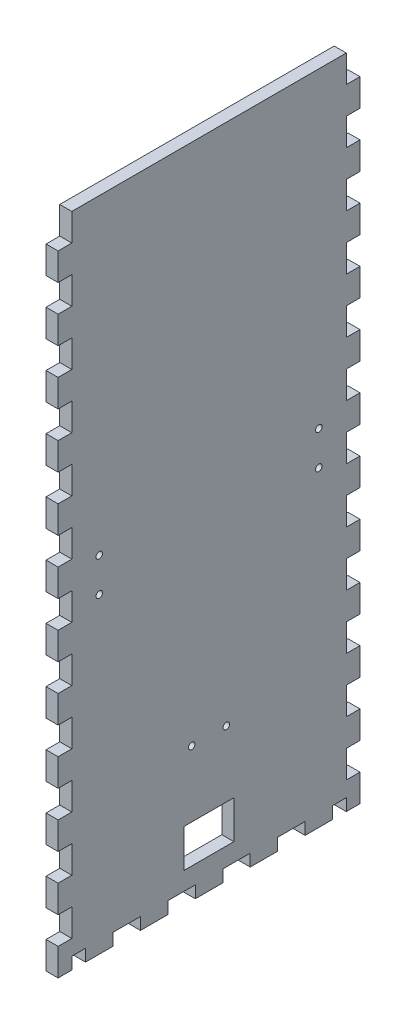
from build123d import *

# Parameters (mm, degrees)
SKETCH1_W              = 273.05
SKETCH1_H              = 139.7
BOSS_EXTRUDE1_DEPTH    = 5.588
SKETCH2_W              = 273.05
SKETCH2_H              = 139.7
SKETCH2_W_2            = 261.874
SKETCH2_H_2            = 128.524
BOSS_EXTRUDE2_DEPTH    = 298.45
SKETCH3_W              = 6.35
SKETCH3_H              = 16.933333333
SKETCH3_H_2            = 16.933333334
DOOR_SLOT_DEPTH        = 12.7
DOOR_GUIDE_HOLES_REACH = 361.255
SKETCH4_W              = 6.35
SKETCH4_H              = 15.875
LEVER_HOLES_W          = 9.652
LEVER_HOLES_H          = 6.35
LEVER_HOLES_W_2        = 6.35
CUT_EXTRUDE1_DEPTH     = 362.378293578
CUT_EXTRUDE3_REACH     = 416.577
SKETCH8_R              = 3.175
SKETCH16_W             = 327.238778096
SKETCH16_H             = 314.471565403
CUT_EXTRUDE10_DEPTH    = 362.378293578
LEFT_RIGHT_W           = 6.35
LEFT_RIGHT_H           = 5.588
LEFT_RIGHT_W_2         = 12.7
LEFT_RIGHT_H_2         = 12.66825
CUT_EXTRUDE11_DEPTH    = 415.577411883
SKETCH17_R             = 1.5
SKETCH17_W             = 23
SKETCH17_H             = 17.61800007
CUT_EXTRUDE12_DEPTH    = 313.00857951


with BuildPart() as part:
    # Sketch1 → Boss-Extrude1 (new body)
    with BuildSketch(Plane(origin=(0, 0, 0), x_dir=(1, 0, 0), z_dir=(0, 1, 0))):
        Rectangle(SKETCH1_W, SKETCH1_H)
    extrude(amount=BOSS_EXTRUDE1_DEPTH)

    # Sketch2 → Boss-Extrude2 (add)
    with BuildSketch(Plane(origin=(0, 5.588, 0), x_dir=(1, 0, 0), z_dir=(0, 1, 0))):
        Rectangle(SKETCH2_W, SKETCH2_H)
        Rectangle(SKETCH2_W_2, SKETCH2_H_2, mode=Mode.SUBTRACT)
    extrude(amount=BOSS_EXTRUDE2_DEPTH)

    # Sketch3 → Door Slot (cut)
    with BuildSketch(Plane.XY.offset(69.85)):
        with BuildLine():
            Line((-29.337, 282.448), (-29.337, 5.588))
            Line((-29.337, 5.588), (-22.733, 5.588))
            Line((-22.733, 5.588), (-22.733, 291.592))
            Line((-22.733, 291.592), (-42.291, 291.592))
            Line((-42.291, 291.592), (-42.291, 284.988))
            Line((-42.291, 284.988), (-31.877, 284.988))
            ThreePointArc((-31.877, 284.988), (-30.080948776, 284.244051224), (-29.337, 282.448))
        make_face()
        with Locations((-13.208, 80.433333334)):
            Rectangle(SKETCH3_W, SKETCH3_H)
        with Locations((-13.208, 50.8)):
            Rectangle(SKETCH3_W, SKETCH3_H_2)
        with Locations((-13.208, 21.166666667)):
            Rectangle(SKETCH3_W, SKETCH3_H)
    extrude(amount=-DOOR_SLOT_DEPTH, mode=Mode.SUBTRACT)

    # Sketch4 → Door Guide Holes (cut, up to next)
    with BuildSketch(Plane.XY.offset(-64.262), mode=Mode.PRIVATE) as door_guide_holes_sk1:
        with Locations((-45.466, 283.4005)):
            Rectangle(SKETCH4_W, SKETCH4_H)
    door_guide_holes_tool1 = extrude(door_guide_holes_sk1.sketch, amount=-DOOR_GUIDE_HOLES_REACH, mode=Mode.PRIVATE) & part.part
    # Sketch4 → Door Guide Holes (cut, up to next)
    with BuildSketch(Plane.XY.offset(-64.262), mode=Mode.PRIVATE) as door_guide_holes_sk2:
        with Locations((-45.466, 254.8255)):
            Rectangle(SKETCH4_W, SKETCH4_H)
    door_guide_holes_tool2 = extrude(door_guide_holes_sk2.sketch, amount=-DOOR_GUIDE_HOLES_REACH, mode=Mode.PRIVATE) & part.part
    # Sketch4 → Door Guide Holes (cut, up to next)
    with BuildSketch(Plane.XY.offset(-64.262), mode=Mode.PRIVATE) as door_guide_holes_sk3:
        with Locations((-45.466, 226.2505)):
            Rectangle(SKETCH4_W, SKETCH4_H)
    door_guide_holes_tool3 = extrude(door_guide_holes_sk3.sketch, amount=-DOOR_GUIDE_HOLES_REACH, mode=Mode.PRIVATE) & part.part
    # Sketch4 → Door Guide Holes (cut, up to next)
    with BuildSketch(Plane.XY.offset(-64.262), mode=Mode.PRIVATE) as door_guide_holes_sk4:
        with Locations((-45.466, 197.6755)):
            Rectangle(SKETCH4_W, SKETCH4_H)
    door_guide_holes_tool4 = extrude(door_guide_holes_sk4.sketch, amount=-DOOR_GUIDE_HOLES_REACH, mode=Mode.PRIVATE) & part.part
    # Sketch4 → Door Guide Holes (cut, up to next)
    with BuildSketch(Plane.XY.offset(-64.262), mode=Mode.PRIVATE) as door_guide_holes_sk5:
        with Locations((-45.466, 169.1005)):
            Rectangle(SKETCH4_W, SKETCH4_H)
    door_guide_holes_tool5 = extrude(door_guide_holes_sk5.sketch, amount=-DOOR_GUIDE_HOLES_REACH, mode=Mode.PRIVATE) & part.part
    # Sketch4 → Door Guide Holes (cut, up to next)
    with BuildSketch(Plane.XY.offset(-64.262), mode=Mode.PRIVATE) as door_guide_holes_sk6:
        with Locations((-45.466, 140.5255)):
            Rectangle(SKETCH4_W, SKETCH4_H)
    door_guide_holes_tool6 = extrude(door_guide_holes_sk6.sketch, amount=-DOOR_GUIDE_HOLES_REACH, mode=Mode.PRIVATE) & part.part
    # Sketch4 → Door Guide Holes (cut, up to next)
    with BuildSketch(Plane.XY.offset(-64.262), mode=Mode.PRIVATE) as door_guide_holes_sk7:
        with Locations((-45.466, 111.9505)):
            Rectangle(SKETCH4_W, SKETCH4_H)
    door_guide_holes_tool7 = extrude(door_guide_holes_sk7.sketch, amount=-DOOR_GUIDE_HOLES_REACH, mode=Mode.PRIVATE) & part.part
    # Sketch4 → Door Guide Holes (cut, up to next)
    with BuildSketch(Plane.XY.offset(-64.262), mode=Mode.PRIVATE) as door_guide_holes_sk8:
        with Locations((-45.466, 83.3755)):
            Rectangle(SKETCH4_W, SKETCH4_H)
    door_guide_holes_tool8 = extrude(door_guide_holes_sk8.sketch, amount=-DOOR_GUIDE_HOLES_REACH, mode=Mode.PRIVATE) & part.part
    # Sketch4 → Door Guide Holes (cut, up to next)
    with BuildSketch(Plane.XY.offset(-64.262), mode=Mode.PRIVATE) as door_guide_holes_sk9:
        with Locations((-45.466, 54.8005)):
            Rectangle(SKETCH4_W, SKETCH4_H)
    door_guide_holes_tool9 = extrude(door_guide_holes_sk9.sketch, amount=-DOOR_GUIDE_HOLES_REACH, mode=Mode.PRIVATE) & part.part
    # Sketch4 → Door Guide Holes (cut, up to next)
    with BuildSketch(Plane.XY.offset(-64.262), mode=Mode.PRIVATE) as door_guide_holes_sk10:
        with Locations((-45.466, 26.2255)):
            Rectangle(SKETCH4_W, SKETCH4_H)
    door_guide_holes_tool10 = extrude(door_guide_holes_sk10.sketch, amount=-DOOR_GUIDE_HOLES_REACH, mode=Mode.PRIVATE) & part.part
    door_guide_holes_1 = door_guide_holes_tool1.solids().sort_by_distance((-45.466, 283.4005, -64.262))[0]
    add(door_guide_holes_1, mode=Mode.SUBTRACT)
    door_guide_holes_2 = door_guide_holes_tool2.solids().sort_by_distance((-45.466, 254.8255, -64.262))[0]
    add(door_guide_holes_2, mode=Mode.SUBTRACT)
    door_guide_holes_3 = door_guide_holes_tool3.solids().sort_by_distance((-45.466, 226.2505, -64.262))[0]
    add(door_guide_holes_3, mode=Mode.SUBTRACT)
    door_guide_holes_4 = door_guide_holes_tool4.solids().sort_by_distance((-45.466, 197.6755, -64.262))[0]
    add(door_guide_holes_4, mode=Mode.SUBTRACT)
    door_guide_holes_5 = door_guide_holes_tool5.solids().sort_by_distance((-45.466, 169.1005, -64.262))[0]
    add(door_guide_holes_5, mode=Mode.SUBTRACT)
    door_guide_holes_6 = door_guide_holes_tool6.solids().sort_by_distance((-45.466, 140.5255, -64.262))[0]
    add(door_guide_holes_6, mode=Mode.SUBTRACT)
    door_guide_holes_7 = door_guide_holes_tool7.solids().sort_by_distance((-45.466, 111.9505, -64.262))[0]
    add(door_guide_holes_7, mode=Mode.SUBTRACT)
    door_guide_holes_8 = door_guide_holes_tool8.solids().sort_by_distance((-45.466, 83.3755, -64.262))[0]
    add(door_guide_holes_8, mode=Mode.SUBTRACT)
    door_guide_holes_9 = door_guide_holes_tool9.solids().sort_by_distance((-45.466, 54.8005, -64.262))[0]
    add(door_guide_holes_9, mode=Mode.SUBTRACT)
    door_guide_holes_10 = door_guide_holes_tool10.solids().sort_by_distance((-45.466, 26.2255, -64.262))[0]
    add(door_guide_holes_10, mode=Mode.SUBTRACT)
    door_guide_holes = door_guide_holes_1 + door_guide_holes_2 + door_guide_holes_3 + door_guide_holes_4 + door_guide_holes_5 + door_guide_holes_6 + door_guide_holes_7 + door_guide_holes_8 + door_guide_holes_9 + door_guide_holes_10  # Door Guide Holes as one shape, for the pattern or mirror that repeats it

    # Mirror1: Door Guide Holes across plane
    add(door_guide_holes.mirror(Plane.ZY.offset(32.512)), mode=Mode.SUBTRACT)

    # Lever Holes → Cut-Extrude1 (cut, through all)
    with BuildSketch(Plane.XY.offset(69.85)):
        with Locations((54.102, 28.575)):
            Rectangle(LEVER_HOLES_W, LEVER_HOLES_H)
        with Locations((39.3065, 15.875)):
            Rectangle(LEVER_HOLES_W_2, LEVER_HOLES_H)
        with Locations((68.8975, 15.875)):
            Rectangle(LEVER_HOLES_W_2, LEVER_HOLES_H)
    extrude(amount=-CUT_EXTRUDE1_DEPTH, mode=Mode.SUBTRACT)

    # Sketch8 → Cut-Extrude3 (cut, up to next)
    with BuildSketch(Plane.ZY.offset(136.525), mode=Mode.PRIVATE) as cut_extrude3_sk1:
        with Locations((0, 19.05)):
            Circle(SKETCH8_R)
    cut_extrude3_tool1 = extrude(cut_extrude3_sk1.sketch, amount=-CUT_EXTRUDE3_REACH, mode=Mode.PRIVATE) & part.part
    add(cut_extrude3_tool1.solids().sort_by_distance((-136.525, 19.05, 0))[0], mode=Mode.SUBTRACT)

    # Sketch16 → Cut-Extrude10 (cut, through all)
    with BuildSketch(Plane.XY.offset(69.85)):
        with Locations((-32.682389048, 146.802217299)):
            Rectangle(SKETCH16_W, SKETCH16_H)
    extrude(amount=-CUT_EXTRUDE10_DEPTH, mode=Mode.SUBTRACT)

    # Left/Right → Cut-Extrude11 (cut, through all)
    with BuildSketch(Plane.ZY.offset(136.525)):
        with Locations((60.325, 2.794)):
            Rectangle(LEFT_RIGHT_W, LEFT_RIGHT_H)
        with Locations((38.1, 2.794)):
            Rectangle(LEFT_RIGHT_W_2, LEFT_RIGHT_H)
        with Locations((66.675, 19.002375)):
            Rectangle(LEFT_RIGHT_W, LEFT_RIGHT_H_2)
        with Locations((12.7, 2.794)):
            Rectangle(LEFT_RIGHT_W_2, LEFT_RIGHT_H)
        with Locations((66.675, 44.338875)):
            Rectangle(LEFT_RIGHT_W, LEFT_RIGHT_H_2)
        with Locations((-12.7, 2.794)):
            Rectangle(LEFT_RIGHT_W_2, LEFT_RIGHT_H)
        with Locations((66.675, 69.675375)):
            Rectangle(LEFT_RIGHT_W, LEFT_RIGHT_H_2)
        with Locations((-38.1, 2.794)):
            Rectangle(LEFT_RIGHT_W_2, LEFT_RIGHT_H)
        with Locations((66.675, 95.011875)):
            Rectangle(LEFT_RIGHT_W, LEFT_RIGHT_H_2)
        with Locations((-60.325, 2.794)):
            Rectangle(LEFT_RIGHT_W, LEFT_RIGHT_H)
        with Locations((66.675, 120.348375)):
            Rectangle(LEFT_RIGHT_W, LEFT_RIGHT_H_2)
        with Locations((-66.675, 19.002375)):
            Rectangle(LEFT_RIGHT_W, LEFT_RIGHT_H_2)
        with Locations((66.675, 145.684875)):
            Rectangle(LEFT_RIGHT_W, LEFT_RIGHT_H_2)
        with Locations((-66.675, 44.338875)):
            Rectangle(LEFT_RIGHT_W, LEFT_RIGHT_H_2)
        with Locations((66.675, 171.021375)):
            Rectangle(LEFT_RIGHT_W, LEFT_RIGHT_H_2)
        with Locations((-66.675, 69.675375)):
            Rectangle(LEFT_RIGHT_W, LEFT_RIGHT_H_2)
        with Locations((66.675, 196.357875)):
            Rectangle(LEFT_RIGHT_W, LEFT_RIGHT_H_2)
        with Locations((-66.675, 95.011875)):
            Rectangle(LEFT_RIGHT_W, LEFT_RIGHT_H_2)
        with Locations((66.675, 221.694375)):
            Rectangle(LEFT_RIGHT_W, LEFT_RIGHT_H_2)
        with Locations((-66.675, 120.348375)):
            Rectangle(LEFT_RIGHT_W, LEFT_RIGHT_H_2)
        with Locations((66.675, 247.030875)):
            Rectangle(LEFT_RIGHT_W, LEFT_RIGHT_H_2)
        with Locations((-66.675, 145.684875)):
            Rectangle(LEFT_RIGHT_W, LEFT_RIGHT_H_2)
        with Locations((66.675, 272.367375)):
            Rectangle(LEFT_RIGHT_W, LEFT_RIGHT_H_2)
        with Locations((-66.675, 171.021375)):
            Rectangle(LEFT_RIGHT_W, LEFT_RIGHT_H_2)
        with Locations((66.675, 297.703875)):
            Rectangle(LEFT_RIGHT_W, LEFT_RIGHT_H_2)
        with Locations((-66.675, 196.357875)):
            Rectangle(LEFT_RIGHT_W, LEFT_RIGHT_H_2)
        with Locations((-66.675, 221.694375)):
            Rectangle(LEFT_RIGHT_W, LEFT_RIGHT_H_2)
        with Locations((-66.675, 247.030875)):
            Rectangle(LEFT_RIGHT_W, LEFT_RIGHT_H_2)
        with Locations((-66.675, 272.367375)):
            Rectangle(LEFT_RIGHT_W, LEFT_RIGHT_H_2)
        with Locations((-66.675, 297.703875)):
            Rectangle(LEFT_RIGHT_W, LEFT_RIGHT_H_2)
    extrude(amount=-CUT_EXTRUDE11_DEPTH, mode=Mode.SUBTRACT)

    # Sketch17 → Cut-Extrude12 (cut, through all)
    with BuildSketch(Plane(origin=(136.525, 0, 0), x_dir=(0, 0, -1), z_dir=(1, 0, 0))):
        with Locations((-8, 62.088)):
            Circle(SKETCH17_R)
        with Locations((8, 62.088)):
            Circle(SKETCH17_R)
        with Locations((-50.8, 159.894)):
            Circle(SKETCH17_R)
        with Locations((-50.8, 144.144)):
            Circle(SKETCH17_R)
        with Locations(Location((50.8, 144.144, 0), (0, 0, 180))):
            Circle(SKETCH17_R)
        with Locations(Location((50.8, 159.894, 0), (0, 0, 180))):
            Circle(SKETCH17_R)
        with Locations((0, 22.779000035)):
            Rectangle(SKETCH17_W, SKETCH17_H)
    extrude(amount=-CUT_EXTRUDE12_DEPTH, mode=Mode.SUBTRACT)


solid = part.part
